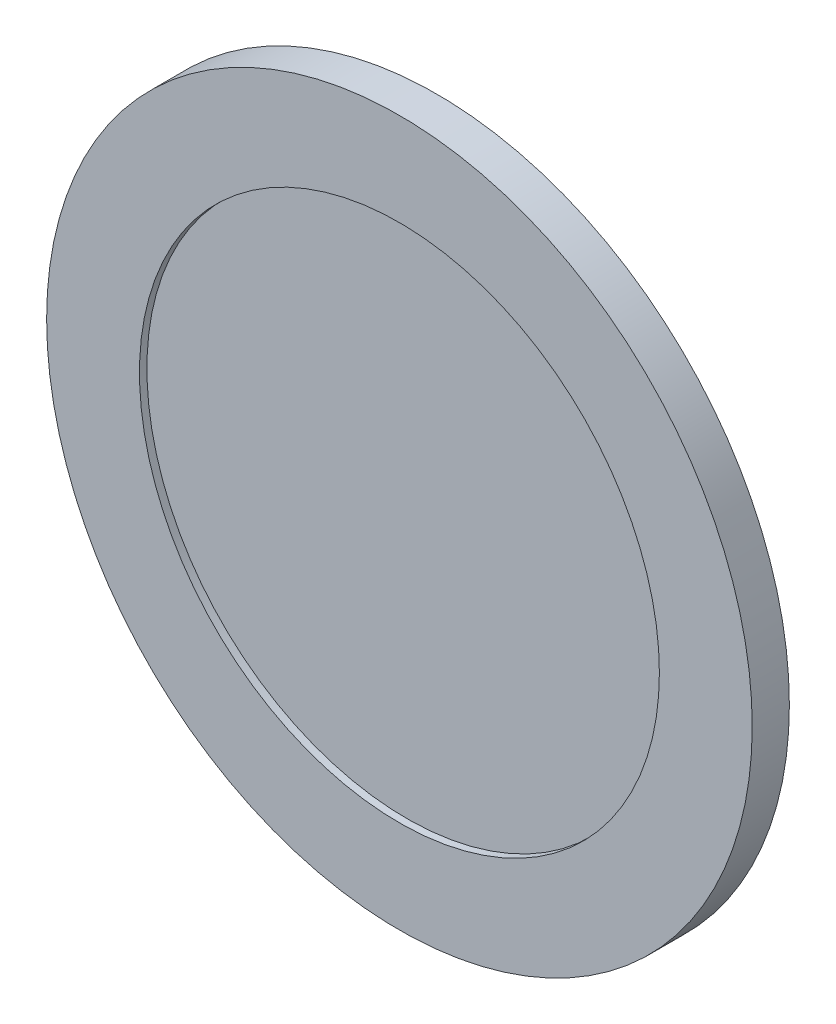
from build123d import *

# Parameters (mm, degrees)
SKETCH1_R           = 9.5
BOSS_EXTRUDE1_DEPTH = 1
SKETCH2_R           = 7
CUT_EXTRUDE1_DEPTH  = 0.2


with BuildPart() as part:
    # Sketch1 → Boss-Extrude1 (new body)
    with BuildSketch(Plane.XY):
        Circle(SKETCH1_R)
    extrude(amount=BOSS_EXTRUDE1_DEPTH)

    # Sketch2 → Cut-Extrude1 (cut)
    with BuildSketch(Plane.XY.offset(1)):
        Circle(SKETCH2_R)
    extrude(amount=-CUT_EXTRUDE1_DEPTH, mode=Mode.SUBTRACT)


solid = part.part
